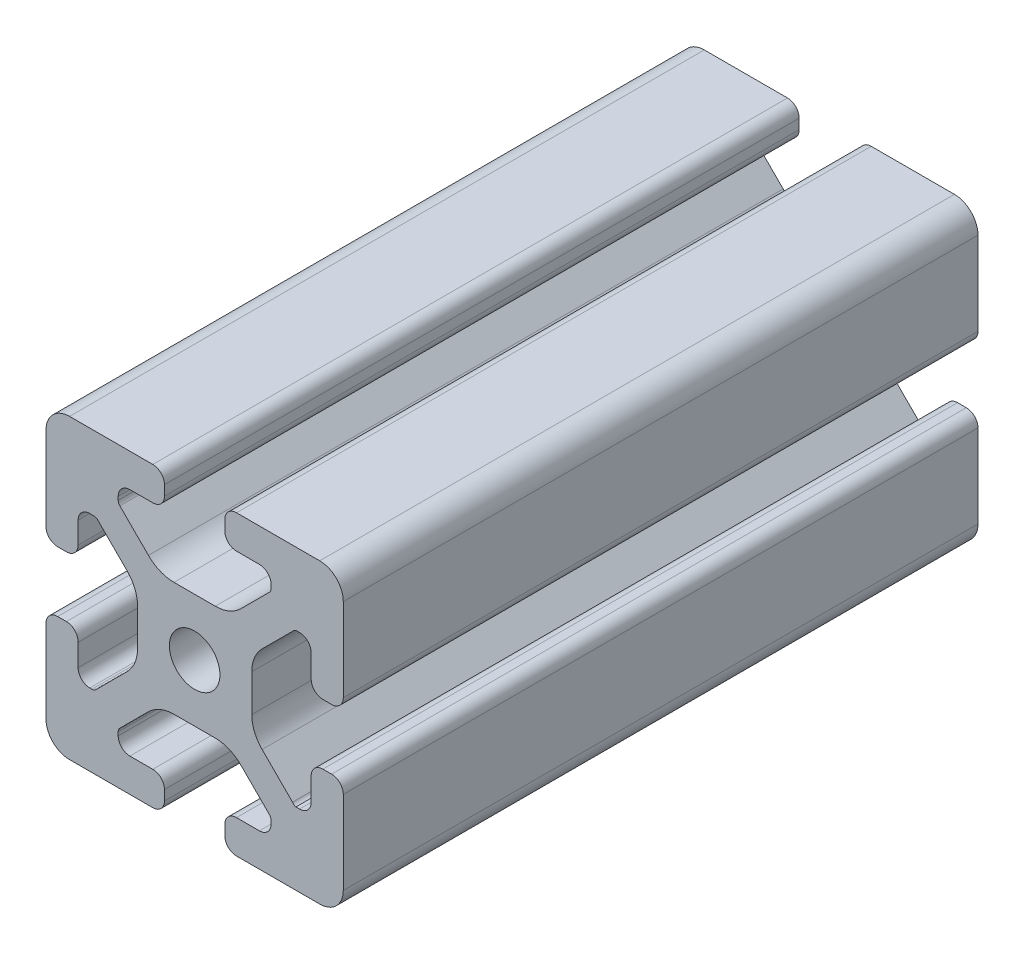
from build123d import *

# Parameters (mm, degrees)
SKETCH1_R      = 3.4
EXTRUDE1_DEPTH = 85.4


with BuildPart() as part:
    # Sketch1 → Extrude1 (new body)
    with BuildSketch(Plane.XY):
        with BuildLine():
            Line((-8.715, -15.524615034), (-5.63, -15.524615034))
            ThreePointArc((-5.63, -15.524615034), (-4.519842354, -15.984457388), (-4.06, -17.094615034))
            Line((-4.06, -17.094615034), (-4.06, -18.43))
            ThreePointArc((-4.06, -18.43), (-4.519842354, -19.540157646), (-5.63, -20))
            Line((-5.63, -20), (-16.674615034, -20))
            ThreePointArc((-16.674615034, -20), (-18.951578385, -19.194274381), (-20, -17.018368134))
            Line((-20, -17.018368134), (-20, -5.757918808))
            ThreePointArc((-20, -5.757918808), (-19.564709668, -4.603883664), (-18.43, -4.120449326))
            Line((-18.43, -4.120449326), (-17.25, -4.120449326))
            ThreePointArc((-17.25, -4.120449326), (-16.115287682, -4.60388249), (-15.67999625, -5.757919334))
            Line((-15.67999625, -5.757919334), (-15.67999625, -8.715399492))
            ThreePointArc((-15.67999625, -8.715399492), (-15.220153896, -9.825557139), (-14.10999625, -10.285399492))
            Line((-14.10999625, -10.285399492), (-13.816898819, -10.285399492))
            ThreePointArc((-13.816898819, -10.285399492), (-13.526061711, -10.227547119), (-13.279501941, -10.062800646))
            Line((-13.279501941, -10.062800646), (-9.076242789, -5.859541495))
            ThreePointArc((-9.076242789, -5.859541495), (-8.046572221, -4.318530588), (-7.685, -2.500784284))
            Line((-7.685, -2.500784284), (-7.685, 2.500784284))
            ThreePointArc((-7.685, 2.500784284), (-8.046572221, 4.318530588), (-9.076242789, 5.859541495))
            Line((-9.076242789, 5.859541495), (-13.040489136, 9.823787841))
            ThreePointArc((-13.040489136, 9.823787841), (-13.354224618, 10.012729352), (-13.71989919, 10.033001362))
            Line((-13.71989919, 10.033001362), (-14.05520779, 10.044710596))
            ThreePointArc((-14.05520779, 10.044710596), (-15.200613642, 9.605030484), (-15.68, 8.475666998))
            Line((-15.68, 8.475666998), (-15.68, 5.572979049))
            ThreePointArc((-15.68, 5.572979049), (-16.139842354, 4.462821403), (-17.25, 4.002979049))
            Line((-17.25, 4.002979049), (-18.43, 4.002979049))
            ThreePointArc((-18.43, 4.002979049), (-19.540157646, 4.462821403), (-20, 5.572979049))
            Line((-20, 5.572979049), (-20, 13.004526564))
            Line((-20, 13.004526564), (-20, 16.83))
            ThreePointArc((-20, 16.83), (-19.071528496, 19.071528496), (-16.83, 20))
            Line((-16.83, 20), (-5.63, 20))
            ThreePointArc((-5.63, 20), (-4.519842354, 19.540157646), (-4.06, 18.43))
            Line((-4.06, 18.43), (-4.06, 17.094615034))
            ThreePointArc((-4.06, 17.094615034), (-4.519842354, 15.984457388), (-5.63, 15.524615034))
            Line((-5.63, 15.524615034), (-8.715, 15.524615034))
            ThreePointArc((-8.715, 15.524615034), (-9.825157646, 15.06477268), (-10.285, 13.954615034))
            Line((-10.285, 13.954615034), (-10.285, 13.492503602))
            ThreePointArc((-10.285, 13.492503602), (-10.227148445, 13.201664194), (-10.062401154, 12.955102448))
            Line((-10.062401154, 12.955102448), (-6.217092793, 9.109794088))
            ThreePointArc((-6.217092793, 9.109794088), (-4.63891877, 8.055291919), (-2.777335583, 7.685))
            Line((-2.777335583, 7.685), (2.777335583, 7.685))
            ThreePointArc((2.777335583, 7.685), (4.63891877, 8.055291919), (6.217092793, 9.109794088))
            Line((6.217092793, 9.109794088), (10.062401154, 12.955102448))
            ThreePointArc((10.062401154, 12.955102448), (10.227148445, 13.201664194), (10.285, 13.492503602))
            Line((10.285, 13.492503602), (10.285, 13.954615034))
            ThreePointArc((10.285, 13.954615034), (9.825157646, 15.06477268), (8.715, 15.524615034))
            Line((8.715, 15.524615034), (5.63, 15.524615034))
            ThreePointArc((5.63, 15.524615034), (4.519842354, 15.984457388), (4.06, 17.094615034))
            Line((4.06, 17.094615034), (4.06, 18.43))
            ThreePointArc((4.06, 18.43), (4.519842354, 19.540157646), (5.63, 20))
            Line((5.63, 20), (12.979635074, 20))
            Line((12.979635074, 20), (16.83, 20))
            ThreePointArc((16.83, 20), (19.071528496, 19.071528496), (20, 16.83))
            Line((20, 16.83), (20, 13.001098436))
            Line((20, 13.001098436), (20, 5.63))
            ThreePointArc((20, 5.63), (19.540157461, 4.519842693), (18.43, 4.060000526))
            Line((18.43, 4.060000526), (17.24999625, 4.060000526))
            ThreePointArc((17.24999625, 4.060000526), (16.139838603, 4.519842879), (15.67999625, 5.630000526))
            Line((15.67999625, 5.630000526), (15.67999625, 8.715399492))
            ThreePointArc((15.67999625, 8.715399492), (15.220153896, 9.825557139), (14.10999625, 10.285399492))
            Line((14.10999625, 10.285399492), (13.816903094, 10.285399492))
            ThreePointArc((13.816903094, 10.285399492), (13.526063686, 10.227547937), (13.279501941, 10.062800646))
            Line((13.279501941, 10.062800646), (9.076242789, 5.859541495))
            ThreePointArc((9.076242789, 5.859541495), (8.046572221, 4.318530588), (7.685, 2.500784284))
            Line((7.685, 2.500784284), (7.685, -2.500784284))
            ThreePointArc((7.685, -2.500784284), (8.046572221, -4.318530588), (9.076242789, -5.859541495))
            Line((9.076242789, -5.859541495), (13.163657296, -9.946956002))
            ThreePointArc((13.163657296, -9.946956002), (13.35903797, -10.160433474), (13.6200547, -10.285399492))
            Line((13.6200547, -10.285399492), (14.10999625, -10.285399492))
            ThreePointArc((14.10999625, -10.285399492), (15.220153896, -9.825557139), (15.67999625, -8.715399492))
            Line((15.67999625, -8.715399492), (15.67999625, -5.630000526))
            ThreePointArc((15.67999625, -5.630000526), (16.139838603, -4.519842879), (17.24999625, -4.060000526))
            Line((17.24999625, -4.060000526), (18.43, -4.060000526))
            ThreePointArc((18.43, -4.060000526), (19.540157461, -4.519842693), (20, -5.63))
            Line((20, -5.63), (20, -16.83))
            ThreePointArc((20, -16.83), (19.071528496, -19.071528496), (16.83, -20))
            Line((16.83, -20), (13, -20))
            Line((13, -20), (5.63, -20))
            ThreePointArc((5.63, -20), (4.519842354, -19.540157646), (4.06, -18.43))
            Line((4.06, -18.43), (4.06, -17.094615034))
            ThreePointArc((4.06, -17.094615034), (4.519842354, -15.984457388), (5.63, -15.524615034))
            Line((5.63, -15.524615034), (8.715, -15.524615034))
            ThreePointArc((8.715, -15.524615034), (9.825157646, -15.06477268), (10.285, -13.954615034))
            Line((10.285, -13.954615034), (10.285, -13.492503602))
            ThreePointArc((10.285, -13.492503602), (10.227148445, -13.201664194), (10.062401154, -12.955102448))
            Line((10.062401154, -12.955102448), (6.217092793, -9.109794088))
            ThreePointArc((6.217092793, -9.109794088), (4.63891877, -8.055291919), (2.777335583, -7.685))
            Line((2.777335583, -7.685), (-2.777335583, -7.685))
            ThreePointArc((-2.777335583, -7.685), (-4.63891877, -8.055291919), (-6.217092793, -9.109794088))
            Line((-6.217092793, -9.109794088), (-10.062401154, -12.955102448))
            ThreePointArc((-10.062401154, -12.955102448), (-10.227148445, -13.201664194), (-10.285, -13.492503602))
            Line((-10.285, -13.492503602), (-10.285, -13.954615034))
            ThreePointArc((-10.285, -13.954615034), (-9.825157646, -15.06477268), (-8.715, -15.524615034))
        make_face()
        Circle(SKETCH1_R, mode=Mode.SUBTRACT)
    extrude(amount=-EXTRUDE1_DEPTH)


solid = part.part
